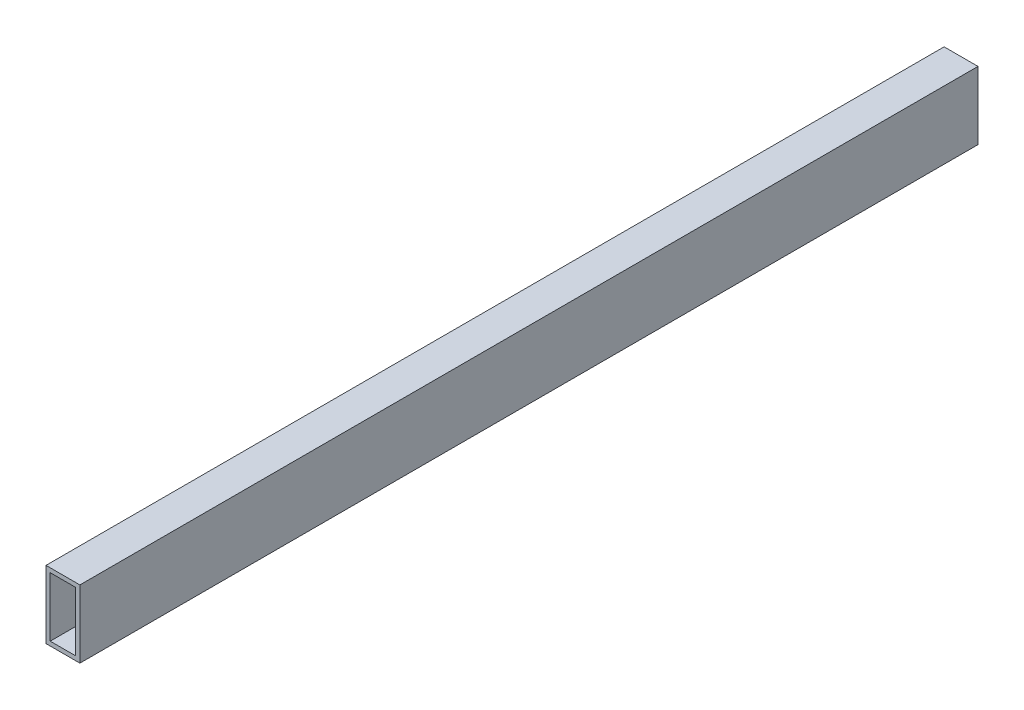
from build123d import *

# Parameters (mm, degrees)
SKETCH1_W           = 25.4
SKETCH1_H           = 50.8
SKETCH1_W_2         = 19.05
SKETCH1_H_2         = 44.45
BOSS_EXTRUDE1_DEPTH = 673.1


with BuildPart() as part:
    # Sketch1 → Boss-Extrude1 (new body)
    with BuildSketch(Plane.XY):
        Rectangle(SKETCH1_W, SKETCH1_H)
        Rectangle(SKETCH1_W_2, SKETCH1_H_2, mode=Mode.SUBTRACT)
    extrude(amount=BOSS_EXTRUDE1_DEPTH)


solid = part.part
